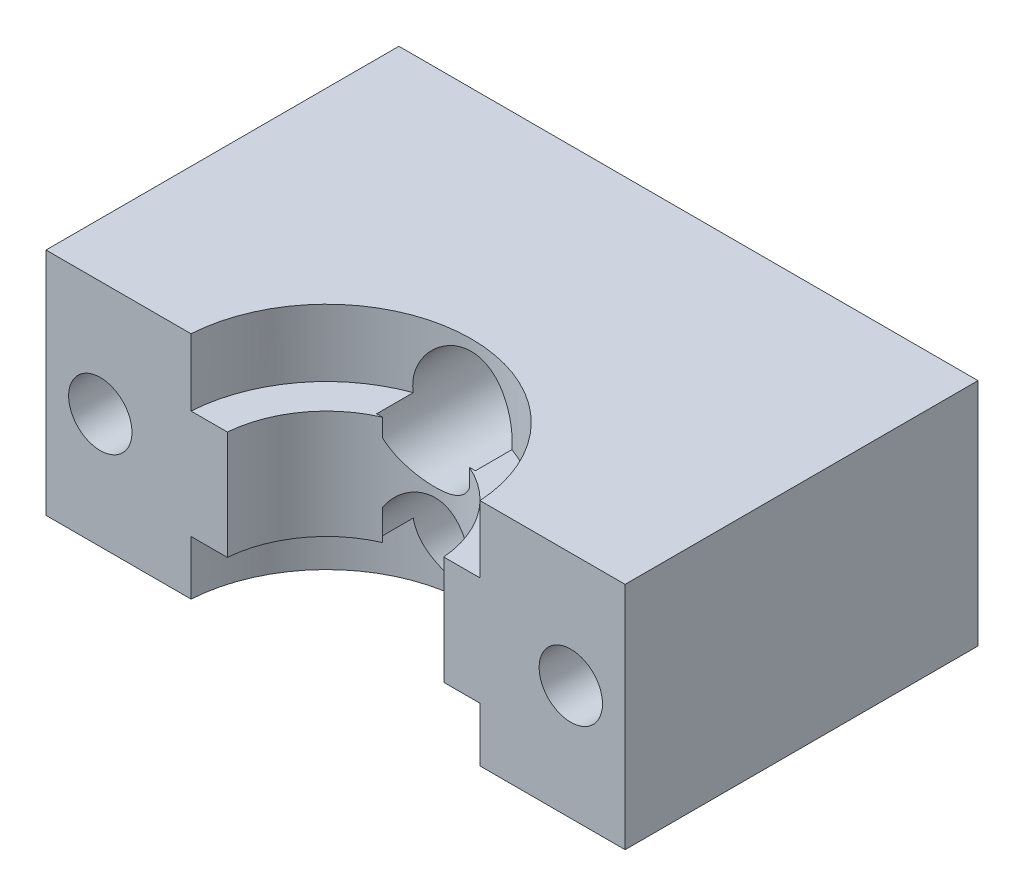
from build123d import *

# Parameters (mm, degrees)
SKETCH2_W           = 32
SKETCH2_H           = 12.7
SKETCH2_R           = 1.75
BOSS_EXTRUDE1_DEPTH = 19.5
SKETCH3_R           = 1.75
CUT_EXTRUDE1_DEPTH  = 20.5
CUT_EXTRUDE2_DEPTH  = 4
SKETCH5_R           = 8
CUT_EXTRUDE3_DEPTH  = 3.7
SKETCH9_R           = 6
CUT_EXTRUDE5_DEPTH  = 6
SKETCH10_R          = 8
CUT_EXTRUDE6_DEPTH  = 4
SKETCH6_R           = 2.75
CUT_EXTRUDE4_DEPTH  = 7.5


with BuildPart() as part:
    # Sketch2 → Boss-Extrude1 (new body)
    with BuildSketch(Plane.XY):
        Rectangle(SKETCH2_W, SKETCH2_H)
        with Locations((0, 3)):
            Circle(SKETCH2_R, mode=Mode.SUBTRACT)
        with Locations((0, -3)):
            Circle(SKETCH2_R, mode=Mode.SUBTRACT)
    extrude(amount=BOSS_EXTRUDE1_DEPTH)

    # Sketch3 → Cut-Extrude1 (cut, through all)
    with BuildSketch(Plane.XY.offset(19.5)):
        with Locations((-13, 0)):
            Circle(SKETCH3_R)
        with Locations((13, 0)):
            Circle(SKETCH3_R)
    extrude(amount=-CUT_EXTRUDE1_DEPTH, mode=Mode.SUBTRACT)

    # Sketch4 → Cut-Extrude2 (cut)
    with BuildSketch(Plane(origin=(0, 0, 0), x_dir=(-1, 0, 0), z_dir=(0, 0, -1))):
        Polygon((-10.25, -1.58771324), (-10.25, 1.58771324), (-13, 3.175426481), (-15.75, 1.58771324), (-15.75, -1.58771324), (-13, -3.175426481), align=None)
        Polygon((13, -3.175426481), (15.75, -1.58771324), (15.75, 1.58771324), (13, 3.175426481), (10.25, 1.58771324), (10.25, -1.58771324), align=None)
    extrude(amount=-CUT_EXTRUDE2_DEPTH, mode=Mode.SUBTRACT)

    # Sketch5 → Cut-Extrude3 (cut)
    with BuildSketch(Plane(origin=(0, 6.35, 0), x_dir=(1, 0, 0), z_dir=(0, 1, 0))):
        with Locations((0, -20)):
            Circle(SKETCH5_R)
    extrude(amount=-CUT_EXTRUDE3_DEPTH, mode=Mode.SUBTRACT)

    # Sketch9 → Cut-Extrude5 (cut)
    with BuildSketch(Plane(origin=(0, 2.65, 0), x_dir=(1, 0, 0), z_dir=(0, 1, 0))):
        with Locations((0, -20)):
            Circle(SKETCH9_R)
    extrude(amount=-CUT_EXTRUDE5_DEPTH, mode=Mode.SUBTRACT)

    # Sketch10 → Cut-Extrude6 (cut, through all)
    with BuildSketch(Plane(origin=(0, -3.35, 0), x_dir=(1, 0, 0), z_dir=(0, 1, 0))):
        with Locations((0, -20)):
            Circle(SKETCH10_R)
    extrude(amount=-CUT_EXTRUDE6_DEPTH, mode=Mode.SUBTRACT)

    # Sketch6 → Cut-Extrude4 (cut)
    with BuildSketch(Plane.XY.offset(14.5)):
        with Locations((0, 3)):
            Circle(SKETCH6_R)
        with Locations((0, -3)):
            Circle(SKETCH6_R)
    extrude(amount=-CUT_EXTRUDE4_DEPTH, mode=Mode.SUBTRACT)


solid = part.part
